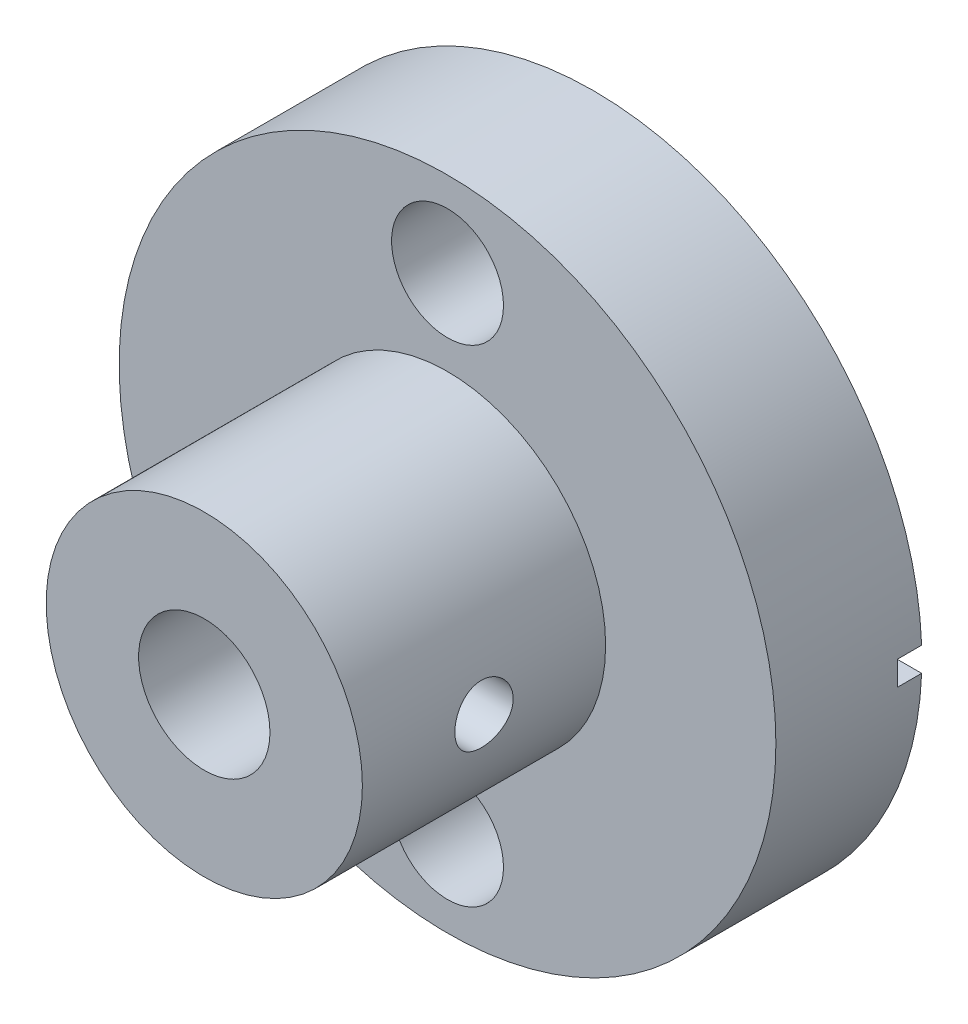
from build123d import *

# Parameters (mm, degrees)
SKETCH2_R               = 13.5
BOSS_EXTRUDE1_DEPTH     = 6
SKETCH3_R               = 6.5
SKETCH3_R_2             = 2.5
BOSS_EXTRUDE2_DEPTH     = 10
CUT_EXTRUDE1_DEPTH      = 25
CUT_EXTRUDE1_DEPTH_BACK = 25
SKETCH4_R               = 1.2
CUT_EXTRUDE3_DEPTH      = 50
CUT_EXTRUDE3_DEPTH_BACK = 20
SKETCH6_R               = 2.7
SKETCH5_R               = 2.3
CUT_EXTRUDE4_DEPTH      = 10
SKETCH8_W               = 10
SKETCH8_H               = 1
CUT_EXTRUDE5_DEPTH      = 1


with BuildPart() as part:
    # Sketch2 → Boss-Extrude1 (new body)
    with BuildSketch(Plane.XY):
        Circle(SKETCH2_R)
    extrude(amount=BOSS_EXTRUDE1_DEPTH)

    # Sketch3 → Boss-Extrude2 (add)
    with BuildSketch(Plane.XY.offset(6)):
        Circle(SKETCH3_R)
        Circle(SKETCH3_R_2, mode=Mode.SUBTRACT)
    extrude(amount=BOSS_EXTRUDE2_DEPTH)

    # Sketch4 → Cut-Extrude1 (cut, two sides: drawn at the far end of the back side and taken through both)
    with BuildSketch(Plane(origin=(0, 0, 0), x_dir=(0, -1, 0), z_dir=(1, 0, 0)).offset(-CUT_EXTRUDE1_DEPTH_BACK)):
        with Locations((0, -11)):
            Circle(SKETCH4_R)
    extrude(amount=CUT_EXTRUDE1_DEPTH + CUT_EXTRUDE1_DEPTH_BACK, mode=Mode.SUBTRACT)

    # Sketch6 → Cut-Extrude3 (cut, two sides: drawn at the far end of the back side and taken through both)
    with BuildSketch(Plane.XY.offset(6).offset(-CUT_EXTRUDE3_DEPTH_BACK)):
        Circle(SKETCH6_R)
    extrude(amount=CUT_EXTRUDE3_DEPTH + CUT_EXTRUDE3_DEPTH_BACK, mode=Mode.SUBTRACT)

    # Sketch5 → Cut-Extrude4 (cut)
    with BuildSketch(Plane.XY.offset(6)):
        with Locations((0, 10)):
            Circle(SKETCH5_R)
    cut_extrude4 = extrude(amount=-CUT_EXTRUDE4_DEPTH, mode=Mode.SUBTRACT)

    # Mirror1: Cut-Extrude4 across plane
    add(cut_extrude4.mirror(Plane.ZX), mode=Mode.SUBTRACT)

    # Sketch8 → Cut-Extrude5 (cut)
    with BuildSketch(Plane(origin=(0, 0, 0), x_dir=(-1, 0, 0), z_dir=(0, 0, -1))):
        with Locations((-13.5, 0)):
            Rectangle(SKETCH8_W, SKETCH8_H)
    cut_extrude5 = extrude(amount=-CUT_EXTRUDE5_DEPTH, mode=Mode.SUBTRACT)

    # Mirror2: Cut-Extrude5 across plane
    add(cut_extrude5.mirror(Plane(origin=(0, 0, 0), x_dir=(0, 0, 1), z_dir=(1, 0, 0))), mode=Mode.SUBTRACT)


solid = part.part
